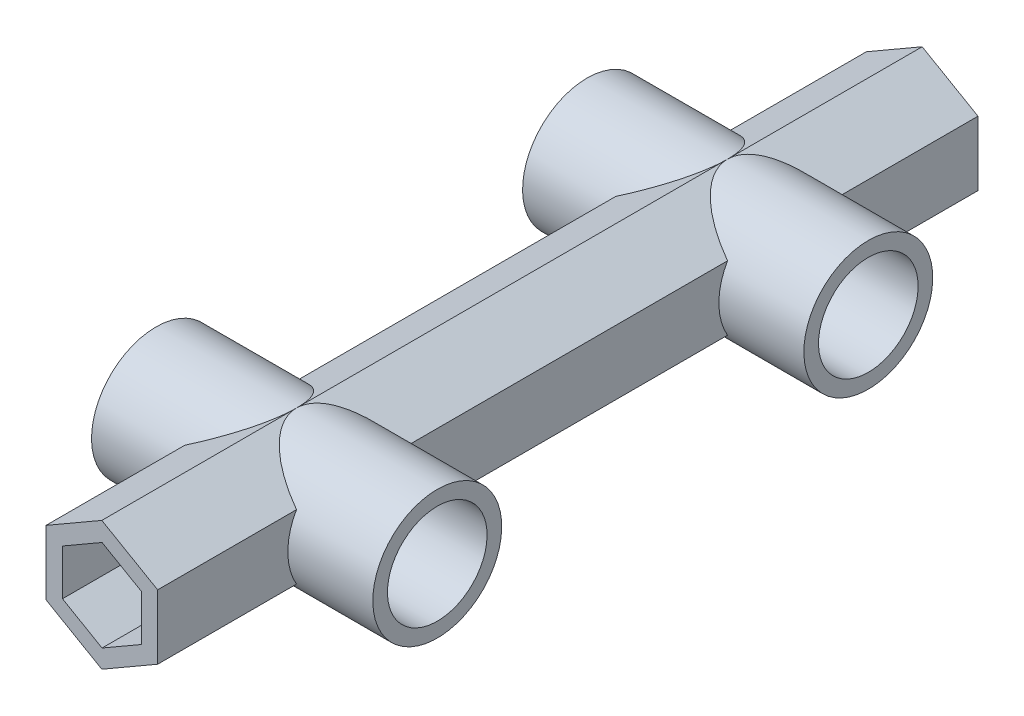
from build123d import *

# Parameters (mm, degrees)
BOSS_EXTRUDE2_DEPTH      = 70
CUT_EXTRUDE6_DEPTH       = 15
CUT_EXTRUDE7_DEPTH       = 15
BOSS_EXTRUDE3_DEPTH      = 14.5
BOSS_EXTRUDE3_DEPTH_BACK = 33.5
SKETCH3_R                = 11
SKETCH3_R_2              = 8.5
SKETCH12_R               = 8.5
SKETCH12_R_2             = 9
CUT_EXTRUDE8_DEPTH       = 79.378887463


with BuildPart() as part:
    # Sketch1_3 → Boss-Extrude2 (new, symmetric)
    with BuildSketch(Plane.XY):
        Polygon((-9.526279442, -5.5), (0, -11), (9.526279442, -5.5), (9.526279442, 5.5), (0, 11), (-9.526279442, 5.5), align=None)
    extrude(amount=BOSS_EXTRUDE2_DEPTH, both=True)

    # Sketch10 → Cut-Extrude6 (cut)
    with BuildSketch(Plane.XY.offset(70)):
        Polygon((0.040785795, -7.840785795), (6.795783944, -3.940785795), (6.795783944, 3.859214205), (0.040785795, 7.759214205), (-6.714212355, 3.859214205), (-6.714212355, -3.940785795), align=None)
    extrude(amount=-CUT_EXTRUDE6_DEPTH, mode=Mode.SUBTRACT)

    # Sketch11 → Cut-Extrude7 (cut)
    with BuildSketch(Plane(origin=(0, 0, -70), x_dir=(-1, 0, 0), z_dir=(0, 0, -1))):
        Polygon((0, -7.820392897), (6.75499815, -3.920392897), (6.75499815, 3.879607103), (0, 7.779607103), (-6.75499815, 3.879607103), (-6.75499815, -3.920392897), align=None)
    extrude(amount=-CUT_EXTRUDE7_DEPTH, mode=Mode.SUBTRACT)

    # Sketch3 → Boss-Extrude3 (add, two sides: drawn at the far end of the back side and taken through both)
    # profile 1 of 2: a face of its own
    with BuildSketch(Plane(origin=(9.526279442, 0, 0), x_dir=(0, 0, -1), z_dir=(1, 0, 0)).offset(-BOSS_EXTRUDE3_DEPTH_BACK)):
        with Locations((-36.78, 0)):
            Circle(SKETCH3_R)
        with Locations((-36.78, 0)):
            Circle(SKETCH3_R_2, mode=Mode.SUBTRACT)
    # profile 2 of 2: a face of its own
    with BuildSketch(Plane(origin=(9.526279442, 0, 0), x_dir=(0, 0, -1), z_dir=(1, 0, 0)).offset(-BOSS_EXTRUDE3_DEPTH_BACK)):
        with Locations((36.78, 0)):
            Circle(SKETCH3_R)
        with Locations((36.78, 0)):
            Circle(SKETCH3_R_2, mode=Mode.SUBTRACT)
    extrude(amount=BOSS_EXTRUDE3_DEPTH + BOSS_EXTRUDE3_DEPTH_BACK)

    # Sketch12 → Cut-Extrude8 (cut, through all)
    with BuildSketch(Plane(origin=(9.526279442, 0, 0), x_dir=(0, 0, -1), z_dir=(1, 0, 0))):
        with Locations((-36.78, 0)):
            Circle(SKETCH12_R)
        with Locations((36.78, 0)):
            Circle(SKETCH12_R_2)
    extrude(amount=-CUT_EXTRUDE8_DEPTH, mode=Mode.SUBTRACT)


solid = part.part
